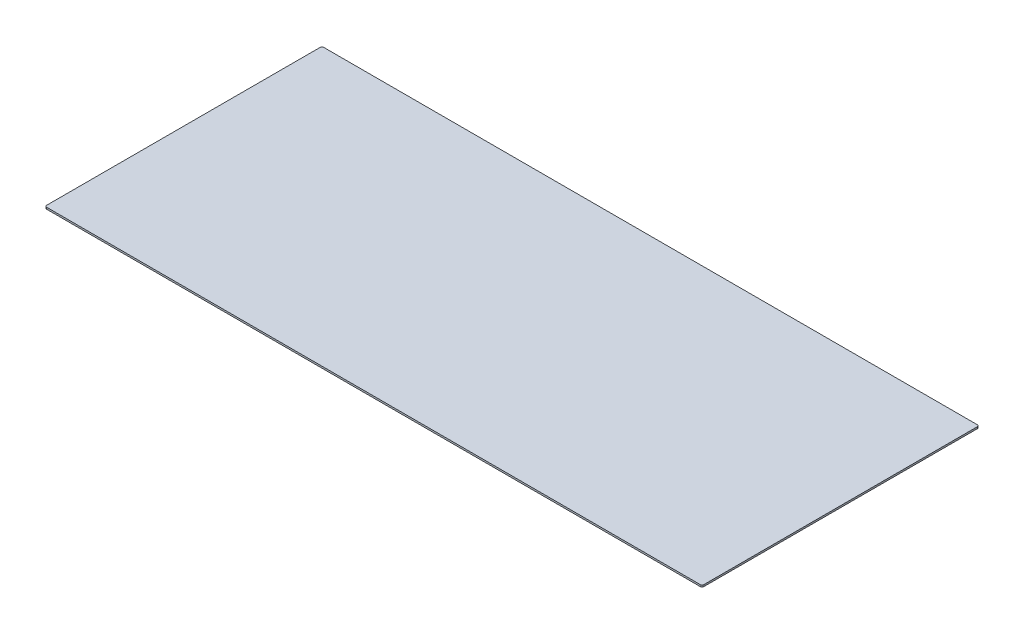
from build123d import *

# Parameters (mm, degrees)
BOSS_EXTRUDE1_DEPTH = 3.175


with BuildPart() as part:
    # Sketch1 → Boss-Extrude1 (new body)
    with BuildSketch(Plane(origin=(0, 0, 0), x_dir=(1, 0, 0), z_dir=(0, 1, 0))):
        with BuildLine():
            Line((-587.375, -248.92), (587.375, -248.92))
            ThreePointArc((587.375, -248.92), (589.62006403, -247.99006403), (590.55, -245.745))
            Line((590.55, -245.745), (590.55, 245.745))
            ThreePointArc((590.55, 245.745), (589.62006403, 247.99006403), (587.375, 248.92))
            Line((587.375, 248.92), (-587.375, 248.92))
            ThreePointArc((-587.375, 248.92), (-589.62006403, 247.99006403), (-590.55, 245.745))
            Line((-590.55, 245.745), (-590.55, -245.745))
            ThreePointArc((-590.55, -245.745), (-589.62006403, -247.99006403), (-587.375, -248.92))
        make_face()
    extrude(amount=BOSS_EXTRUDE1_DEPTH)


solid = part.part
